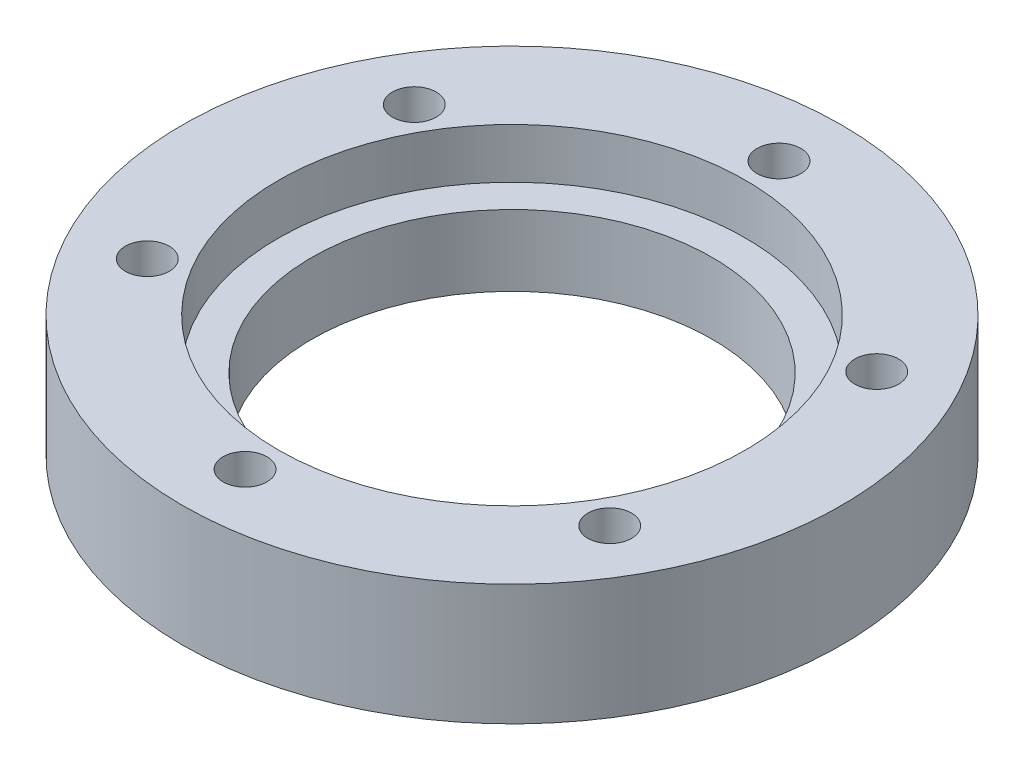
from build123d import *

# Parameters (mm, degrees)
SKETCH1_R                                = 79
BOSS_EXTRUDE1_DEPTH                      = 29
CBORE_FOR_M10_HEX_HEAD_BOLT1_D           = 96
CBORE_FOR_M10_HEX_HEAD_BOLT1_CBORE_D     = 112
CBORE_FOR_M10_HEX_HEAD_BOLT1_CBORE_DEPTH = 12
TAP_DRILL_FOR_M12X1_5_TAP1_D             = 10.5


with BuildPart() as part:
    # Sketch1 → Boss-Extrude1 (new body)
    with BuildSketch(Plane(origin=(0, 0, 0), x_dir=(1, 0, 0), z_dir=(0, 1, 0))):
        Circle(SKETCH1_R)
    extrude(amount=BOSS_EXTRUDE1_DEPTH)

    # CBORE for M10 Hex Head Bolt1 (through all)
    with Locations(Plane(origin=(0, 29, 0), x_dir=(1, 0, 0), z_dir=(0, 1, 0))):
        with Locations((0, 0)):
            CounterBoreHole(CBORE_FOR_M10_HEX_HEAD_BOLT1_D / 2, CBORE_FOR_M10_HEX_HEAD_BOLT1_CBORE_D / 2, CBORE_FOR_M10_HEX_HEAD_BOLT1_CBORE_DEPTH)

    # Tap Drill for M12x1.5 Tap1 (through all)
    with Locations(Plane(origin=(0, 29, 0), x_dir=(1, 0, 0), z_dir=(0, 1, 0))):
        with Locations((55.425625842, -32), (0, -64), (-55.425625842, -32), (-55.425625842, 32), (0, 64), (55.425625842, 32), (0, 0)):
            Hole(TAP_DRILL_FOR_M12X1_5_TAP1_D / 2)


solid = part.part
